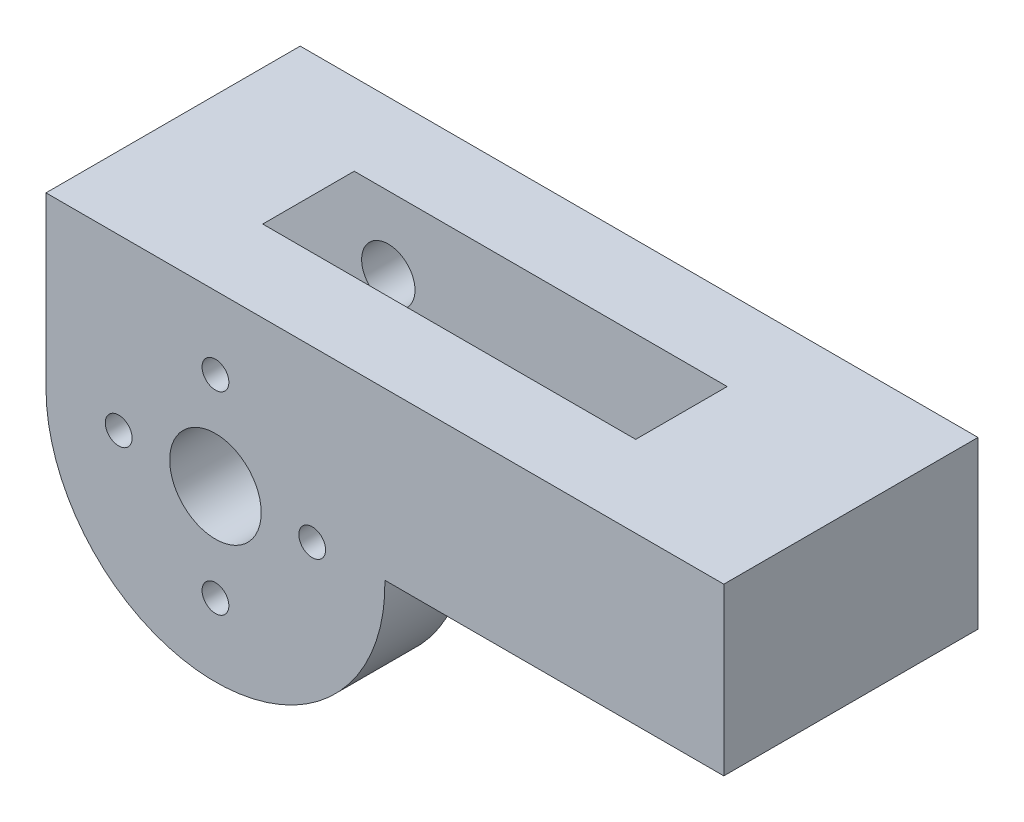
from build123d import *

# Parameters (mm, degrees)
SKETCH1_R           = 3.429
BOSS_EXTRUDE1_DEPTH = 9.525
CUT_EXTRUDE1_START  = -9.525
CUT_EXTRUDE1_DEPTH  = 3.429
SKETCH4_R           = 1.004000024
CUT_EXTRUDE2_DEPTH  = 20.05
SKETCH5_R           = 2.000000064
CUT_EXTRUDE3_DEPTH  = 14.954


with BuildPart() as part:
    # Sketch1 → Boss-Extrude1 (new body, symmetric)
    with BuildSketch(Plane.XY):
        with BuildLine():
            Line((-12.7, 0), (-12.7, 12.7))
            Line((-12.7, 12.7), (38.1, 12.7))
            Line((38.1, 12.7), (38.1, 0.254))
            Line((38.1, 0.254), (12.697459746, 0.254))
            ThreePointArc((12.697459746, 0.254), (0.127006351, -12.699364921), (-12.7, 0))
        make_face()
        Circle(SKETCH1_R, mode=Mode.SUBTRACT)
    extrude(amount=BOSS_EXTRUDE1_DEPTH, both=True)

    # Sketch3 → Cut-Extrude1 (cut, symmetric)
    with BuildSketch(Plane.XY.offset(9.525).offset(CUT_EXTRUDE1_START)):
        with BuildLine():
            Line((25.4, 12.7), (25.4, 0.254))
            Line((25.4, 0.254), (12.951509565, 0.254))
            ThreePointArc((12.951509565, 0.254), (-9.069614104, -9.24922786), (0, 12.954))
            Line((0, 12.954), (0, 12.7))
            Line((0, 12.7), (25.4, 12.7))
        make_face()
    extrude(amount=CUT_EXTRUDE1_DEPTH, both=True, mode=Mode.SUBTRACT)

    # Sketch4 → Cut-Extrude2 (cut, through all)
    with BuildSketch(Plane.XY.offset(9.525)):
        with Locations((7.249999978, 0)):
            Circle(SKETCH4_R)
        with Locations((0, -7.249999978)):
            Circle(SKETCH4_R)
        with Locations((-7.249999978, 0)):
            Circle(SKETCH4_R)
        with Locations((0, 7.249999978)):
            Circle(SKETCH4_R)
    extrude(amount=-CUT_EXTRUDE2_DEPTH, mode=Mode.SUBTRACT)

    # Sketch5 → Cut-Extrude3 (cut)
    with BuildSketch(Plane(origin=(0, 0, -9.525), x_dir=(-1, 0, 0), z_dir=(0, 0, -1))):
        with Locations((7.249999978, 0)):
            Circle(SKETCH5_R)
        with Locations((0, -7.249999978)):
            Circle(SKETCH5_R)
        with Locations((-7.249999978, 0)):
            Circle(SKETCH5_R)
        with Locations((0, 7.249999978)):
            Circle(SKETCH5_R)
    extrude(amount=-CUT_EXTRUDE3_DEPTH, mode=Mode.SUBTRACT)


solid = part.part
